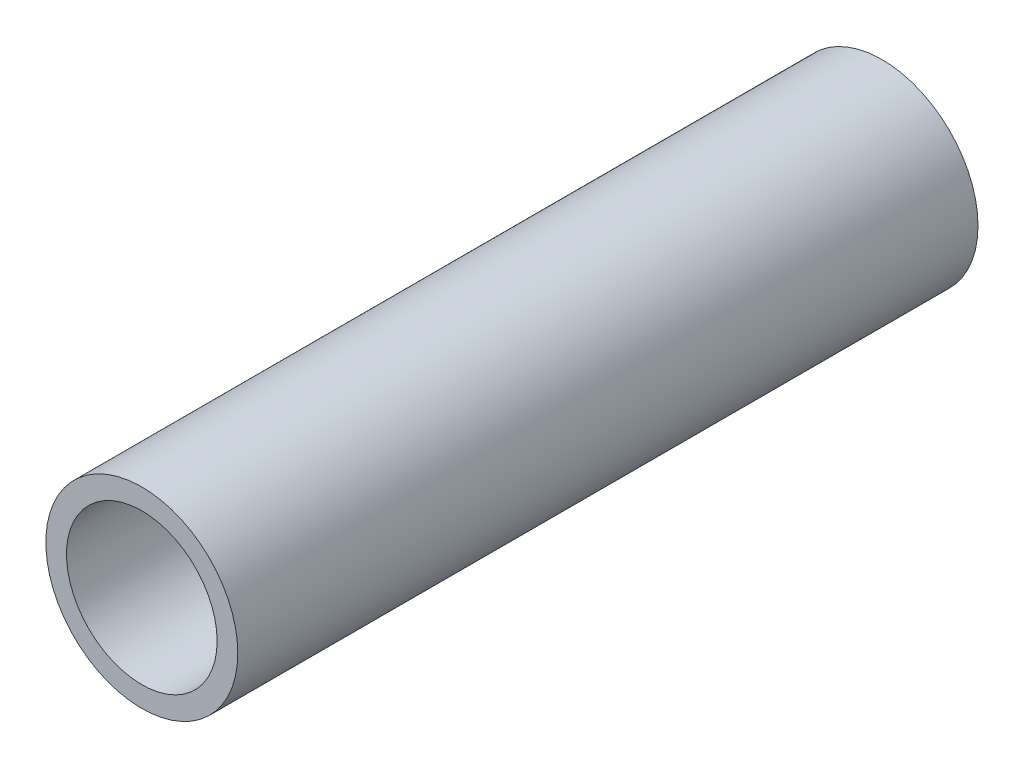
from build123d import *

# Parameters (mm, degrees)
SKETCH3_R                = 13.335
SKETCH3_R_2              = 10.4648
BOSS_EXTRUDE1_DEPTH      = 762
BOSS_EXTRUDE1_DEPTH_BACK = 762
SKETCH4_R                = 13.335
CUT_EXTRUDE2_DEPTH       = 1421.145469


with BuildPart() as part:
    # Sketch3 → Boss-Extrude1 (new body, two sides)
    with BuildSketch(Plane.XY) as boss_extrude1_sk:
        Circle(SKETCH3_R)
        Circle(SKETCH3_R_2, mode=Mode.SUBTRACT)
    extrude(amount=BOSS_EXTRUDE1_DEPTH)
    extrude(boss_extrude1_sk.sketch, amount=-BOSS_EXTRUDE1_DEPTH_BACK)

    # Sketch4 → Cut-Extrude2 (cut)
    with BuildSketch(Plane.XY.offset(762)):
        Circle(SKETCH4_R)
    extrude(amount=-CUT_EXTRUDE2_DEPTH, mode=Mode.SUBTRACT)


solid = part.part
